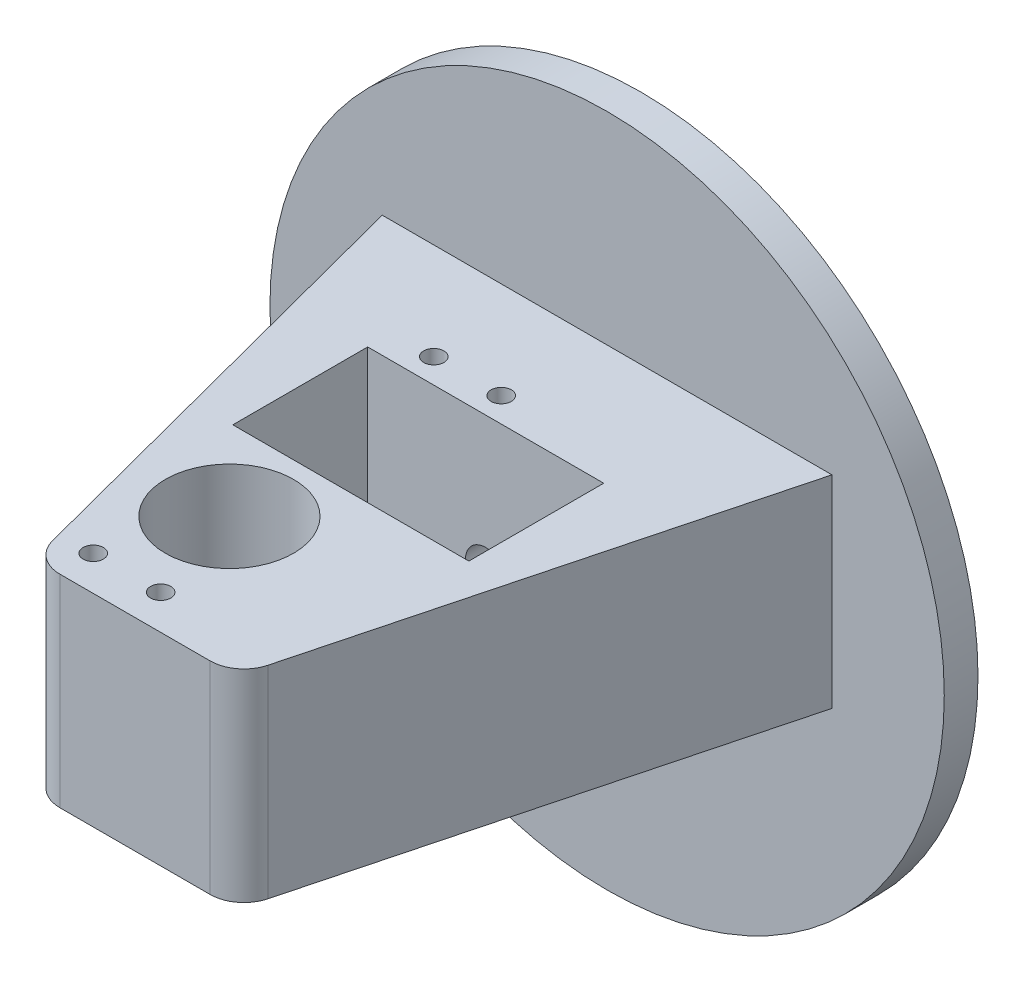
from build123d import *

# Parameters (mm, degrees)
BOSS_EXTRUDE1_DEPTH   = 40
SKETCH9_R             = 9.5
CUT_EXTRUDE5_DEPTH    = 20
SKETCH10_R            = 5
CUT_EXTRUDE6_DEPTH    = 21
SKETCH11_R            = 9.5
CUT_EXTRUDE7_DEPTH    = 16
SKETCH14_W            = 35
SKETCH14_H            = 20
CUT_EXTRUDE9_DEPTH    = 41
SKETCH15_R            = 3
CUT_EXTRUDE10_DEPTH   = 25
SKETCH16_R            = 50
SKETCH16_R_2          = 3
BOSS_EXTRUDE3_DEPTH   = 5
SKETCH17_W            = 69.206254994
SKETCH17_H            = 74.867048483
CUT_EXTRUDE11_DEPTH   = 10
SKETCH18_R            = 1.5
CUT_EXTRUDE12_DEPTH   = 10
SKETCH20_R            = 1.5
CUT_EXTRUDE13_DEPTH   = 10
BODY_MOVE_COPY1_ANGLE = 180


with BuildPart() as part:
    # Sketch1 → Boss-Extrude1 (new body)
    with BuildSketch(Plane(origin=(0, 0, 0), x_dir=(1, 0, 0), z_dir=(0, 1, 0))):
        with BuildLine():
            Line((-11.141347684, 70), (11.141347684, 70))
            ThreePointArc((11.141347684, 70), (14.196114062, 68.958333283), (15.978061054, 66.267360951))
            Line((15.978061054, 66.267360951), (33.342055813, 0))
            Line((33.342055813, 0), (-33.342055813, 0))
            Line((-33.342055813, 0), (-15.978061054, 66.267360951))
            ThreePointArc((-15.978061054, 66.267360951), (-14.196114062, 68.958333283), (-11.141347684, 70))
        make_face()
    extrude(amount=BOSS_EXTRUDE1_DEPTH)

    # Sketch9 → Cut-Extrude5 (cut)
    with BuildSketch(Plane.XZ):
        with Locations((-6, -50)):
            Circle(SKETCH9_R)
    extrude(amount=-CUT_EXTRUDE5_DEPTH, mode=Mode.SUBTRACT)

    # Sketch10 → Cut-Extrude6 (cut, through all)
    with BuildSketch(Plane.XZ.offset(-20)):
        with Locations((-6, -50)):
            Circle(SKETCH10_R)
    extrude(amount=-CUT_EXTRUDE6_DEPTH, mode=Mode.SUBTRACT)

    # Sketch11 → Cut-Extrude7 (cut)
    with BuildSketch(Plane(origin=(0, 40, 0), x_dir=(1, 0, 0), z_dir=(0, 1, 0))):
        with Locations((-6, 50)):
            Circle(SKETCH11_R)
    extrude(amount=-CUT_EXTRUDE7_DEPTH, mode=Mode.SUBTRACT)

    # Sketch14 → Cut-Extrude9 (cut, through all)
    with BuildSketch(Plane(origin=(0, 40, 0), x_dir=(1, 0, 0), z_dir=(0, 1, 0))):
        with Locations((0, 28)):
            Rectangle(SKETCH14_W, SKETCH14_H)
    extrude(amount=-CUT_EXTRUDE9_DEPTH, mode=Mode.SUBTRACT)

    # Sketch15 → Cut-Extrude10 (cut)
    with BuildSketch(Plane.XY):
        with Locations((0, 20)):
            Circle(SKETCH15_R)
    extrude(amount=-CUT_EXTRUDE10_DEPTH, mode=Mode.SUBTRACT)

    # Sketch16 → Boss-Extrude3 (add)
    with BuildSketch(Plane.XY):
        with Locations((0, 20)):
            Circle(SKETCH16_R)
        with Locations((0, 20)):
            Circle(SKETCH16_R_2, mode=Mode.SUBTRACT)
    extrude(amount=BOSS_EXTRUDE3_DEPTH)

    # Sketch17 → Cut-Extrude11 (cut)
    with BuildSketch(Plane(origin=(0, 40, 0), x_dir=(1, 0, 0), z_dir=(0, 1, 0))):
        with Locations((1.261071684, 37.433524242)):
            Rectangle(SKETCH17_W, SKETCH17_H)
    extrude(amount=-CUT_EXTRUDE11_DEPTH, mode=Mode.SUBTRACT)

    # Sketch18 → Cut-Extrude12 (cut)
    with BuildSketch(Plane.XZ):
        with Locations((-1.350189987, -64.85)):
            Circle(SKETCH18_R)
        with Locations((-11.350189987, -64.85)):
            Circle(SKETCH18_R)
    extrude(amount=-CUT_EXTRUDE12_DEPTH, mode=Mode.SUBTRACT)

    # Sketch20 → Cut-Extrude13 (cut)
    with BuildSketch(Plane.XZ):
        with Locations((-11.350189987, -14.35)):
            Circle(SKETCH20_R)
        with Locations((-1.350189987, -14.35)):
            Circle(SKETCH20_R)
    extrude(amount=-CUT_EXTRUDE13_DEPTH, mode=Mode.SUBTRACT)


with BuildPart() as part_1:
    # Body-Move/Copy1: moved
    add(part.part.rotate(Axis((0, 20, -32.5), (1, 0, 0)), BODY_MOVE_COPY1_ANGLE))


with BuildPart() as part_2:
    # Body-Move/Copy2: moved
    add(part_1.part.moved(Location((0, -20, 70))))


solid = part_2.part
